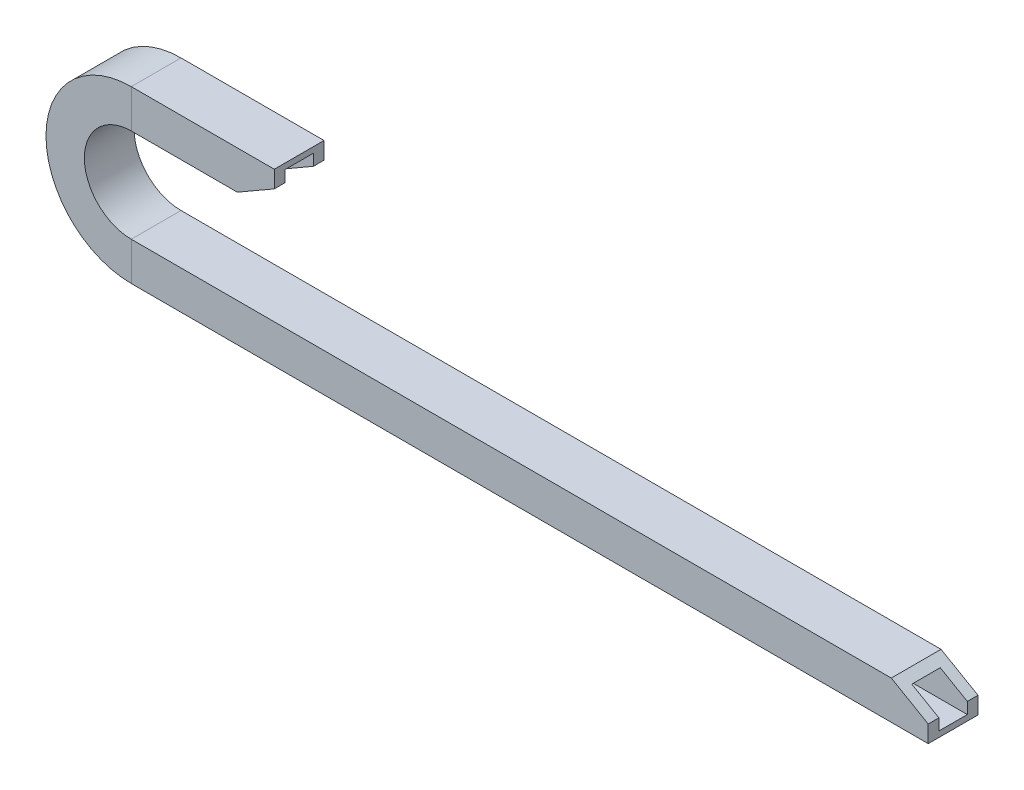
from build123d import *

# Parameters (mm, degrees)
SKETCH2_W           = 17.5
SKETCH2_H           = 13.5
BOSS_EXTRUDE1_DEPTH = 17.5
SKETCH4_W           = 10
SKETCH4_H           = 9.5


with BuildPart() as part:
    # Sweep1: sweep along a path in Sketch1
    with BuildLine(Plane.XY) as sweep1_path:
        Line((-26.2, 66.98), (-54.503416211, 66.98))
        ThreePointArc((-54.503416211, 66.98), (-84.493416211, 36.99), (-54.503416211, 7))
        Line((-54.503416211, 7), (203.81795526, 7))
    # Sketch2 → Sweep1 (sweep)
    with BuildSketch(Plane(origin=(203.81795526, 7, 0), x_dir=(0, 0, 1), z_dir=(-1, 0, 0))):
        with Locations((0, 6.75)):
            Rectangle(SKETCH2_W, SKETCH2_H)
    sweep(path=sweep1_path.line)

    # Sketch3 → Boss-Extrude1 (add)
    with BuildSketch(Plane.XY.offset(8.75)):
        Polygon((-26.2, 66.98), (-26.2, 53.48), (-17.2, 53.48), (-4.2, 60.98), (-4.2, 66.98), align=None)
        Polygon((203.81795526, 20.5), (203.81795526, 7), (225.81795526, 7), (225.81795526, 13), (212.81795526, 20.5), align=None)
    extrude(amount=-BOSS_EXTRUDE1_DEPTH)

    # Cut-Sweep2: sweep along a path in Sketch5
    with BuildLine(Plane.XY) as cut_sweep2_path:
        Line((-4.2, 66.98), (-26.2, 66.98))
        Line((-26.2, 66.98), (-54.503416211, 66.98))
        ThreePointArc((-54.503416211, 66.98), (-84.493416211, 36.99), (-54.503416211, 7))
        Line((-54.503416211, 7), (203.81795526, 7))
        Line((203.81795526, 7), (225.81795526, 7))
    # Sketch4 → Cut-Sweep2 (sweep, cut)
    with BuildSketch(Plane(origin=(225.81795526, 0, 0), x_dir=(0, 0, -1), z_dir=(1, 0, 0))):
        with Locations((0, 13.75)):
            Rectangle(SKETCH4_W, SKETCH4_H)
    sweep(path=cut_sweep2_path.line, mode=Mode.SUBTRACT)


solid = part.part
